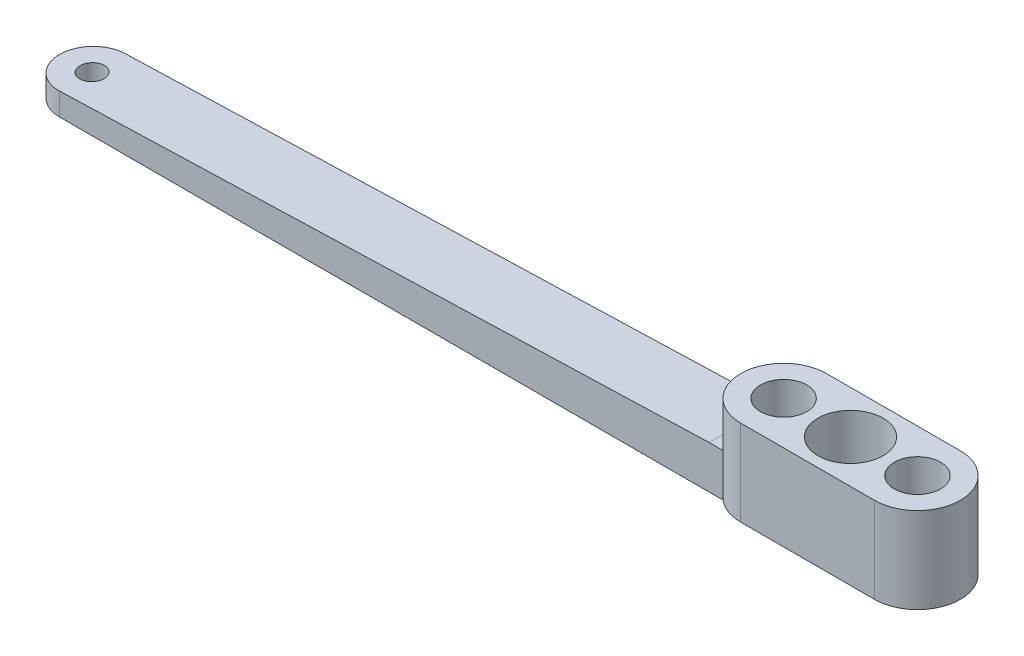
from build123d import *

# Parameters (mm, degrees)
SKETCH1_R               = 4.826
SKETCH1_R_2             = 3.429
BOSS_EXTRUDE1_DEPTH     = 12.7
SKETCH2_R               = 3.429
SKETCH2_R_2             = 1.905
BOSS_EXTRUDE2_DEPTH     = 6.35
BOSS_EXTRUDE4_DEPTH     = 6.35
CUT_EXTRUDE1_DEPTH      = 7.35
CUT_EXTRUDE1_DEPTH_BACK = 7.35
SKETCH6_R               = 1.778
CUT_EXTRUDE2_DEPTH      = 6.35


with BuildPart() as part:
    # Sketch1 → Boss-Extrude1 (new body)
    with BuildSketch(Plane(origin=(0, 0, 0), x_dir=(1, 0, 0), z_dir=(0, 1, 0))):
        with BuildLine():
            Line((-9.906, 6.35), (9.906, 6.35))
            ThreePointArc((9.906, 6.35), (16.256, 0), (9.906, -6.35))
            Line((9.906, -6.35), (-9.906, -6.35))
            ThreePointArc((-9.906, -6.35), (-16.256, 0), (-9.906, 6.35))
        make_face()
        Circle(SKETCH1_R, mode=Mode.SUBTRACT)
        with Locations((9.906, 0)):
            Circle(SKETCH1_R_2, mode=Mode.SUBTRACT)
        with Locations((-9.906, 0)):
            Circle(SKETCH1_R_2, mode=Mode.SUBTRACT)
    extrude(amount=BOSS_EXTRUDE1_DEPTH)

    # Sketch2 → Boss-Extrude2 (add)
    with BuildSketch(Plane(origin=(0, 0, 0), x_dir=(1, 0, 0), z_dir=(0, 1, 0))):
        with Locations((-9.906, 0)):
            Circle(SKETCH2_R)
        with Locations((-9.906, 0)):
            Circle(SKETCH2_R_2, mode=Mode.SUBTRACT)
        with Locations((9.906, 0)):
            Circle(SKETCH2_R)
        with Locations((9.906, 0)):
            Circle(SKETCH2_R_2, mode=Mode.SUBTRACT)
    extrude(amount=BOSS_EXTRUDE2_DEPTH)

    # Sketch4 → Boss-Extrude4 (add)
    with BuildSketch(Plane(origin=(0, 0, 0), x_dir=(1, 0, 0), z_dir=(0, 1, 0))):
        with BuildLine():
            ThreePointArc((-14.03301151, -4.826), (-15.67353947, -2.656687497), (-16.256, 0))
            Line((-16.256, 0), (-112.268, 0))
            Line((-112.268, 0), (-112.268, -4.826))
            Line((-112.268, -4.826), (-14.03301151, -4.826))
        make_face()
        with BuildLine():
            Line((-112.268, 0), (-16.256, 0))
            ThreePointArc((-16.256, 0), (-15.67353947, 2.656687497), (-14.03301151, 4.826))
            Line((-14.03301151, 4.826), (-112.268, 4.826))
            ThreePointArc((-112.268, 4.826), (-117.094, 0), (-112.268, -4.826))
            Line((-112.268, -4.826), (-112.268, 0))
        make_face()
    extrude(amount=BOSS_EXTRUDE4_DEPTH)

    # Sketch5 → Cut-Extrude1 (cut, two sides)
    with BuildSketch(Plane.XY) as cut_extrude1_sk:
        Polygon((-117.094, 6.35), (-16.110356901, 6.35), (-117.094, 3.175), align=None)
    extrude(amount=CUT_EXTRUDE1_DEPTH, mode=Mode.SUBTRACT)
    extrude(cut_extrude1_sk.sketch, amount=-CUT_EXTRUDE1_DEPTH_BACK, mode=Mode.SUBTRACT)

    # Sketch6 → Cut-Extrude2 (cut)
    with BuildSketch(Plane(origin=(0, 0, 0), x_dir=(1, 0, 0), z_dir=(0, 1, 0))):
        with Locations((-112.268, 0)):
            Circle(SKETCH6_R)
    extrude(amount=CUT_EXTRUDE2_DEPTH, mode=Mode.SUBTRACT)


solid = part.part
